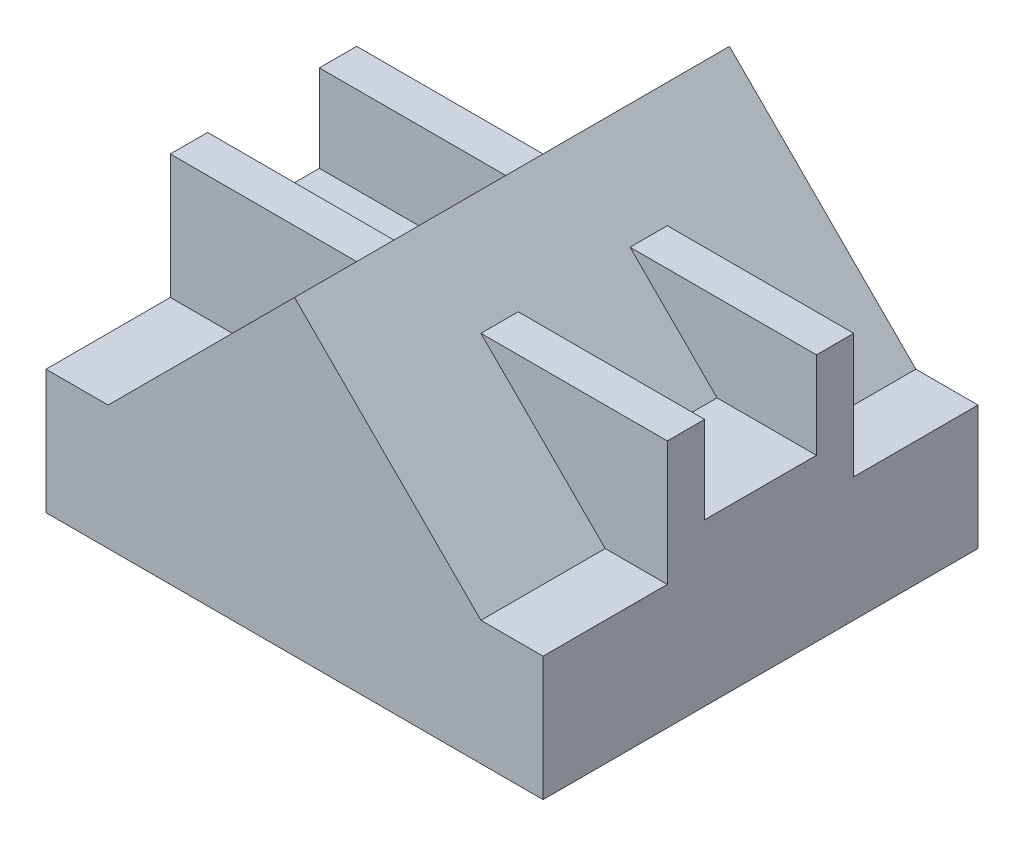
from build123d import *

# Parameters (mm, degrees)
BOSS_EXTRUDE1_DEPTH = 175
BOSS_EXTRUDE2_DEPTH = 200


with BuildPart() as part:
    # Sketch1 → Boss-Extrude1 (new body)
    with BuildSketch(Plane.XY):
        Polygon((75, 25), (100, 25), (100, -25), (-100, -25), (-100, 25), (-75, 25), (0, 100), align=None)
    extrude(amount=BOSS_EXTRUDE1_DEPTH)

    # Sketch2 → Boss-Extrude2 (add)
    with BuildSketch(Plane(origin=(100, 0, 0), x_dir=(0, 0, -1), z_dir=(1, 0, 0))):
        Polygon((-125, 25), (-125, 75), (-110, 75), (-110, 40), (-65, 40), (-65, 75), (-50, 75), (-50, 25), align=None)
    extrude(amount=-BOSS_EXTRUDE2_DEPTH)


solid = part.part
